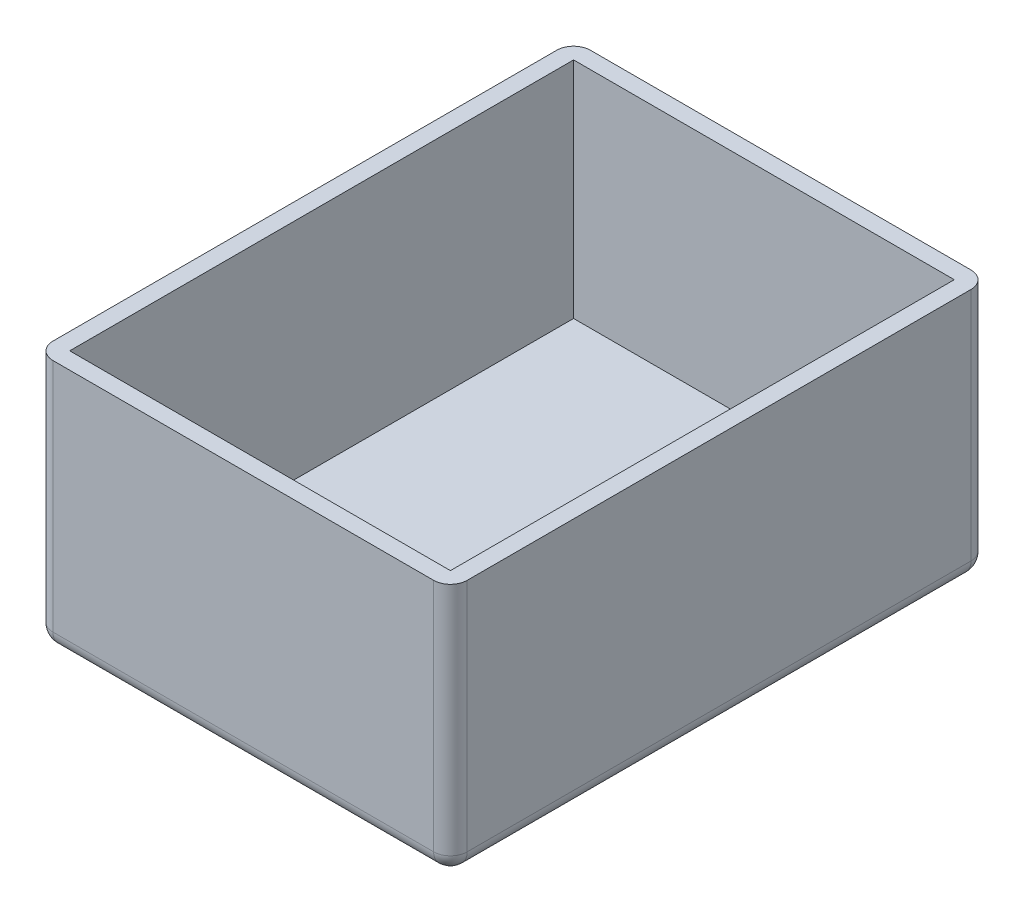
from build123d import *

# Parameters (mm, degrees)
SKETCH1_W           = 74
SKETCH1_H           = 96
BOSS_EXTRUDE1_DEPTH = 45
SKETCH2_W           = 68
SKETCH2_H           = 90
CUT_EXTRUDE1_DEPTH  = 40
SKETCH3_R           = 3
SKETCH3_R_2         = 5
CUT_EXTRUDE2_DEPTH  = 40
FILLET1_R           = 3


with BuildPart() as part:
    # Sketch1 → Boss-Extrude1 (new body)
    with BuildSketch(Plane(origin=(0, 0, 0), x_dir=(1, 0, 0), z_dir=(0, 1, 0))):
        with Locations((37, -48)):
            Rectangle(SKETCH1_W, SKETCH1_H)
    extrude(amount=BOSS_EXTRUDE1_DEPTH)

    # Sketch2 → Cut-Extrude1 (cut)
    with BuildSketch(Plane(origin=(0, 45, 0), x_dir=(1, 0, 0), z_dir=(0, 1, 0))):
        with Locations((37, -48)):
            Rectangle(SKETCH2_W, SKETCH2_H)
    extrude(amount=-CUT_EXTRUDE1_DEPTH, mode=Mode.SUBTRACT)

    # Sketch3 → Cut-Extrude2 (cut)
    with BuildSketch(Plane.XZ):
        with Locations((24, 81.8)):
            Circle(SKETCH3_R)
        with Locations((37, 60)):
            Circle(SKETCH3_R_2)
    extrude(amount=-CUT_EXTRUDE2_DEPTH, mode=Mode.SUBTRACT)

    # Fillet1
    fillet1_edges = [part.edges().sort_by_distance(p)[0] for p in [
        (37, 0, 0),
        (74, 0, 48),
        (37, 0, 96),
        (0, 0, 48),
        (0, 22.5, 0),
        (74, 22.5, 0),
        (74, 22.5, 96),
        (0, 22.5, 96),
    ]]
    fillet(fillet1_edges, radius=FILLET1_R)


solid = part.part
